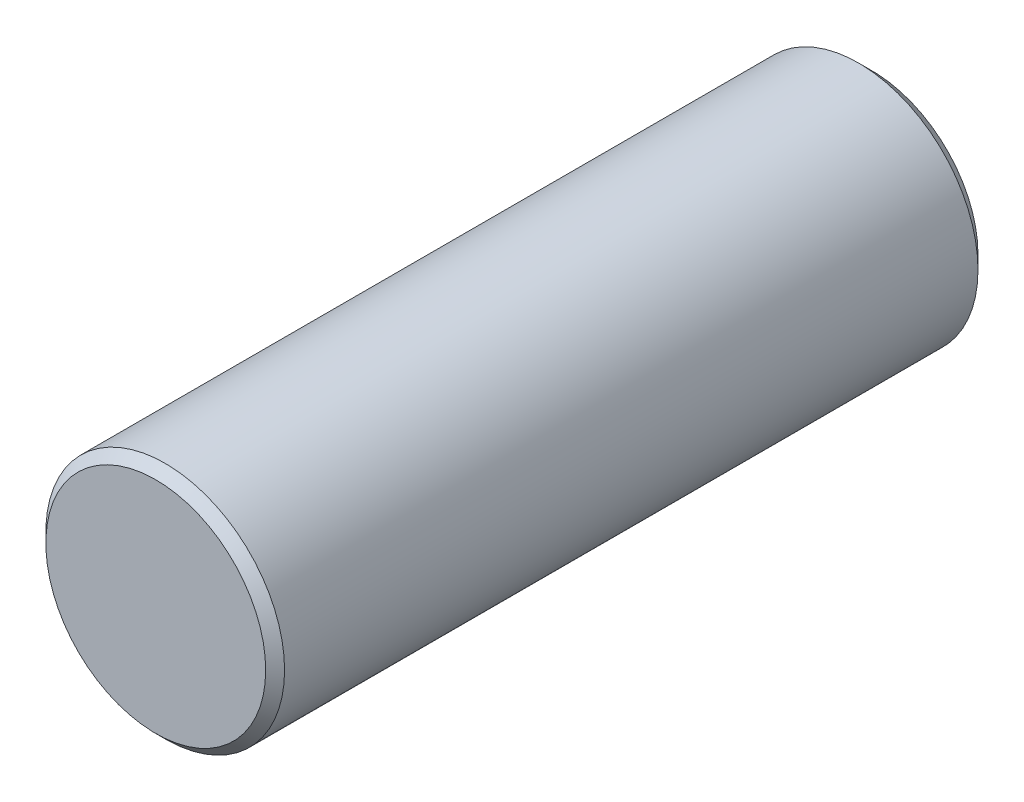
from build123d import *


with BuildPart() as part:
    # Sketch1 → Revolve1 (revolve)
    with BuildSketch(Plane(origin=(0, 0, 0), x_dir=(0, 0, -1), z_dir=(1, 0, 0))):
        Polygon((-9.525, 0), (-9.525, 2.923552829), (-9.273552829, 3.175), (9.1694, 3.175), (9.525, 2.8194), (9.525, 0), align=None)
    revolve(axis=Axis((0, 0, -9.525), (0, 0, 1)))


solid = part.part
